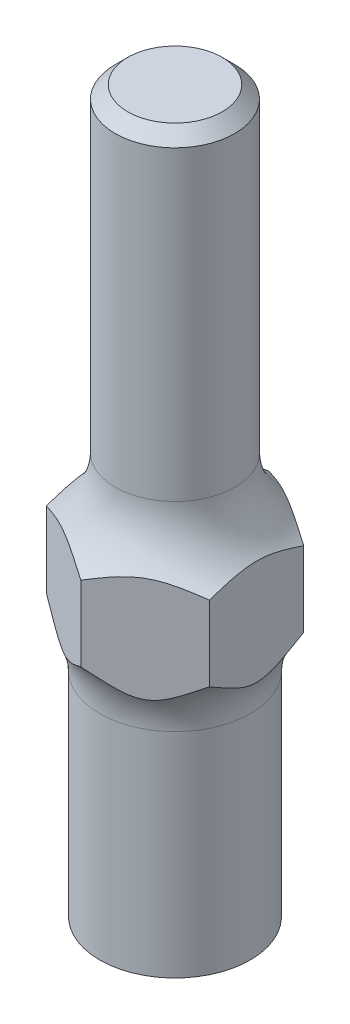
from build123d import *

# Parameters (mm, degrees)
SKETCH1_R                    = 4.7625
BOSS_EXTRUDE1_DEPTH          = 31.4
SKETCH3_R                    = 12.7
BOSS_EXTRUDE2_DEPTH          = 3
SKETCH4_R                    = 6
BOSS_EXTRUDE3_DEPTH          = 26
FILLET1_R                    = 6
F_5_16_24_TAPPED_HOLE1_D     = 6.9088
F_5_16_24_TAPPED_HOLE1_DEPTH = 20
F_5_16_24_TAPPED_HOLE1_TIP   = 2.075612922
SKETCH2_OUTSIDE_W            = 40.942
SKETCH2_OUTSIDE_H            = 40.942
CUT_EXTRUDE1_DEPTH           = 32.4
CUT_EXTRUDE1_DEPTH_BACK      = 27
CHAMFER1_SIZE                = 1


with BuildPart() as part:
    # Sketch1 → Boss-Extrude1 (new body)
    with BuildSketch(Plane(origin=(0, 0, 0), x_dir=(1, 0, 0), z_dir=(0, 1, 0))):
        Circle(SKETCH1_R)
    extrude(amount=BOSS_EXTRUDE1_DEPTH)

    # Sketch3 → Boss-Extrude2 (add)
    with BuildSketch(Plane(origin=(0, 0, 0), x_dir=(1, 0, 0), z_dir=(0, 1, 0))):
        Circle(SKETCH3_R)
    extrude(amount=-BOSS_EXTRUDE2_DEPTH)

    # Sketch4 → Boss-Extrude3 (add)
    with BuildSketch(Plane(origin=(0, 0, 0), x_dir=(1, 0, 0), z_dir=(0, 1, 0))):
        Circle(SKETCH4_R)
    extrude(amount=-BOSS_EXTRUDE3_DEPTH)

    # Fillet1
    fillet1_edges = [part.edges().sort_by_distance(p)[0] for p in [
        (-6, -3, 0),
        (-4.7625, 0, 0),
    ]]
    fillet(fillet1_edges, radius=FILLET1_R)

    # 5/16-24 Tapped Hole1
    with Locations(Plane(origin=(0, -26, 0), x_dir=(-1, 0, 0), z_dir=(0, -1, 0))):
        with Locations((0, 0)):
            Hole(F_5_16_24_TAPPED_HOLE1_D / 2, depth=F_5_16_24_TAPPED_HOLE1_DEPTH)
            with Locations((0, 0, -(F_5_16_24_TAPPED_HOLE1_DEPTH + F_5_16_24_TAPPED_HOLE1_TIP / 2))):  # 118° drill point
                Cone(0, F_5_16_24_TAPPED_HOLE1_D / 2, F_5_16_24_TAPPED_HOLE1_TIP, mode=Mode.SUBTRACT)

    # Sketch2 outside → Cut-Extrude1 (cut, two sides)
    with BuildSketch(Plane(origin=(0, 0, 0), x_dir=(1, 0, 0), z_dir=(0, 1, 0))) as cut_extrude1_sk:
        Rectangle(SKETCH2_OUTSIDE_W, SKETCH2_OUTSIDE_H)
        Polygon((6.5, -3.75277675), (6.5, 3.75277675), (0, 7.505553499), (-6.5, 3.75277675), (-6.5, -3.75277675), (0, -7.505553499), align=None, mode=Mode.SUBTRACT)
    extrude(amount=CUT_EXTRUDE1_DEPTH, mode=Mode.SUBTRACT)
    extrude(cut_extrude1_sk.sketch, amount=-CUT_EXTRUDE1_DEPTH_BACK, mode=Mode.SUBTRACT)

    # Chamfer1
    chamfer1_edges = [part.edges().sort_by_distance(p)[0] for p in [
        (-4.7625, 31.4, 0),
    ]]
    chamfer(chamfer1_edges, length=CHAMFER1_SIZE)


solid = part.part
